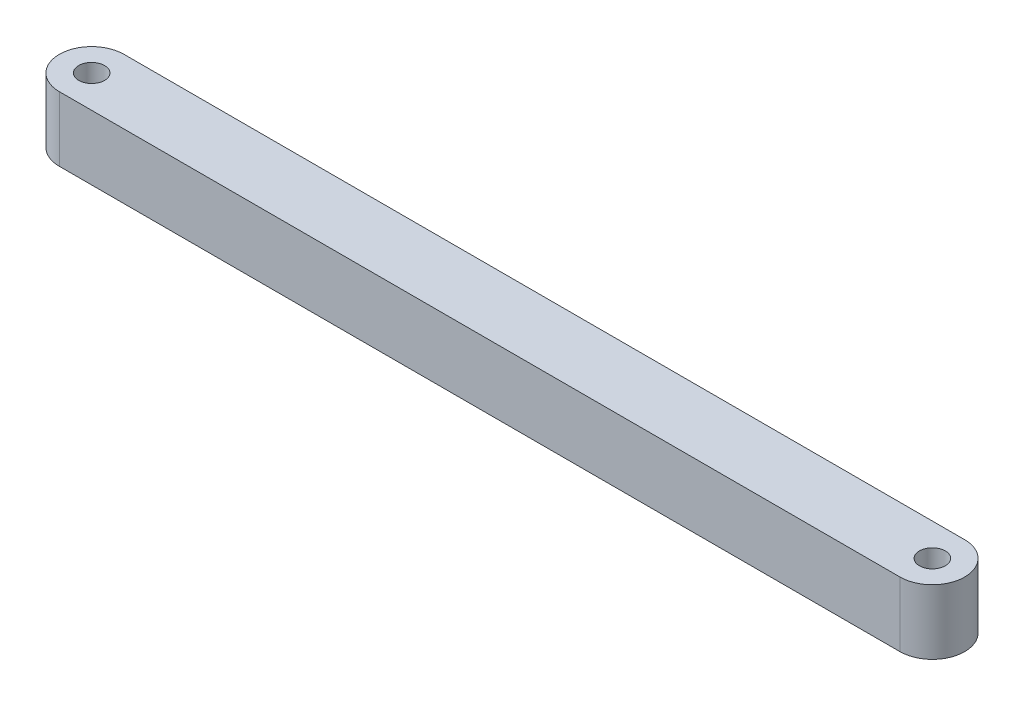
from build123d import *

# Parameters (mm, degrees)
BOSS_EXTRUDE1_DEPTH = 5
CUT_EXTRUDE1_REACH  = 7
SKETCH2_R           = 1


with BuildPart() as part:
    # Sketch1 → Boss-Extrude1 (new body)
    with BuildSketch(Plane(origin=(0, 0, 0), x_dir=(1, 0, 0), z_dir=(0, 1, 0))):
        with BuildLine():
            Line((0, -2.5), (-65, -2.5))
            ThreePointArc((-65, -2.5), (-67.5, 0), (-65, 2.5))
            Line((-65, 2.5), (0, 2.5))
            ThreePointArc((0, 2.5), (2.5, 0), (0, -2.5))
        make_face()
    extrude(amount=BOSS_EXTRUDE1_DEPTH)

    # Sketch2 → Cut-Extrude1 (cut, up to next)
    with BuildSketch(Plane(origin=(0, 5, 0), x_dir=(1, 0, 0), z_dir=(0, 1, 0)), mode=Mode.PRIVATE) as cut_extrude1_sk1:
        with Locations((-65, 0)):
            Circle(SKETCH2_R)
    cut_extrude1_tool1 = extrude(cut_extrude1_sk1.sketch, amount=-CUT_EXTRUDE1_REACH, mode=Mode.PRIVATE) & part.part
    add(cut_extrude1_tool1.solids().sort_by_distance((-65, 5, 0))[0], mode=Mode.SUBTRACT)
    # Sketch2 → Cut-Extrude1 (cut, up to next)
    with BuildSketch(Plane(origin=(0, 5, 0), x_dir=(1, 0, 0), z_dir=(0, 1, 0)), mode=Mode.PRIVATE) as cut_extrude1_sk2:
        Circle(SKETCH2_R)
    cut_extrude1_tool2 = extrude(cut_extrude1_sk2.sketch, amount=-CUT_EXTRUDE1_REACH, mode=Mode.PRIVATE) & part.part
    add(cut_extrude1_tool2.solids().sort_by_distance((0, 5, 0))[0], mode=Mode.SUBTRACT)


solid = part.part
